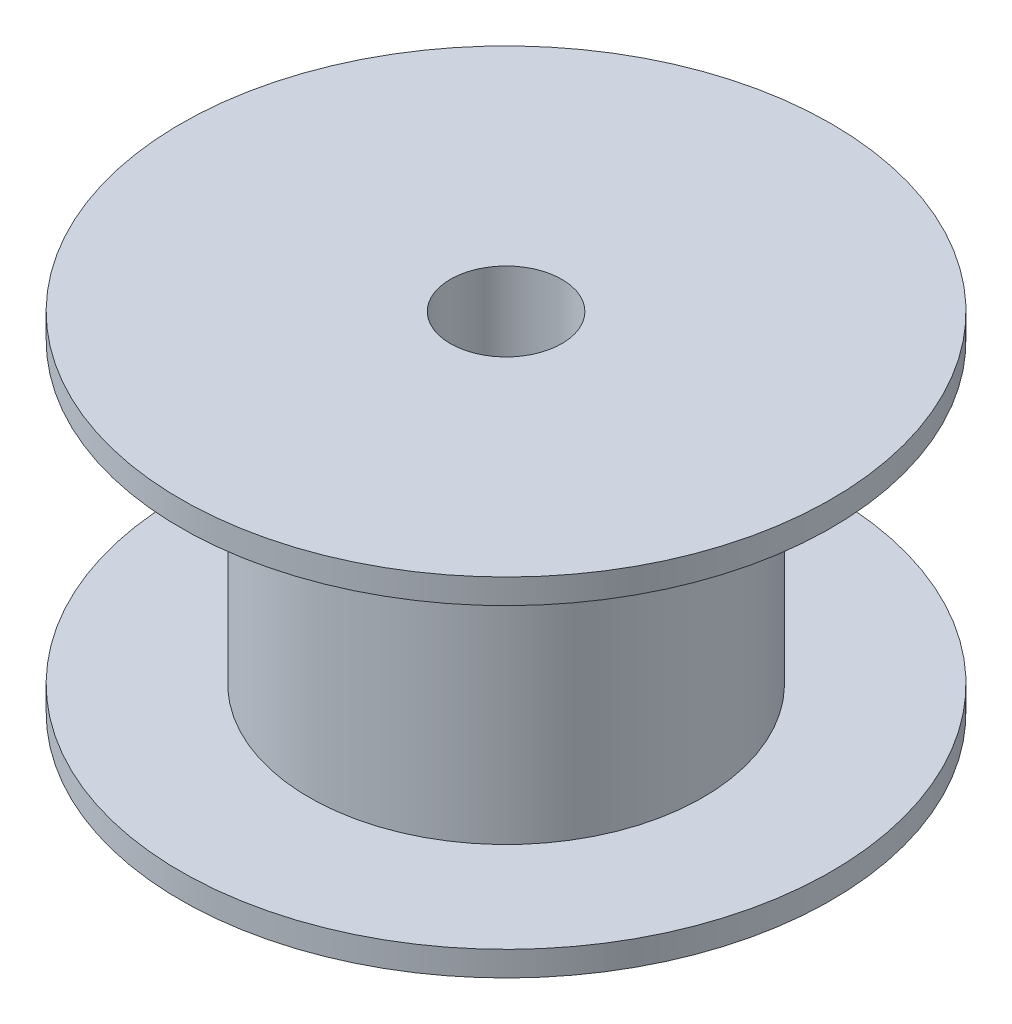
from build123d import *

# Parameters (mm, degrees)
F_8_CLEARANCE_HOLE1_D = 4.4958


with BuildPart() as part:
    # Sketch1 → Revolve1 (revolve)
    with BuildSketch(Plane(origin=(0, 0, 0), x_dir=(0, 0, -1), z_dir=(1, 0, 0))):
        Polygon((0, -7), (0, 7), (-13.112500064, 7), (-13.112500064, 6), (-7.9375, 6), (-7.9375, -6), (-13.112500064, -6), (-13.112500064, -7), align=None)
    revolve(axis=Axis((0, -7, 0), (0, 1, 0)))

    # #8 Clearance Hole1 (through all)
    with Locations(Plane(origin=(0, 7, 0), x_dir=(1, 0, 0), z_dir=(0, 1, 0))):
        with Locations((0, 0)):
            Hole(F_8_CLEARANCE_HOLE1_D / 2)


solid = part.part
